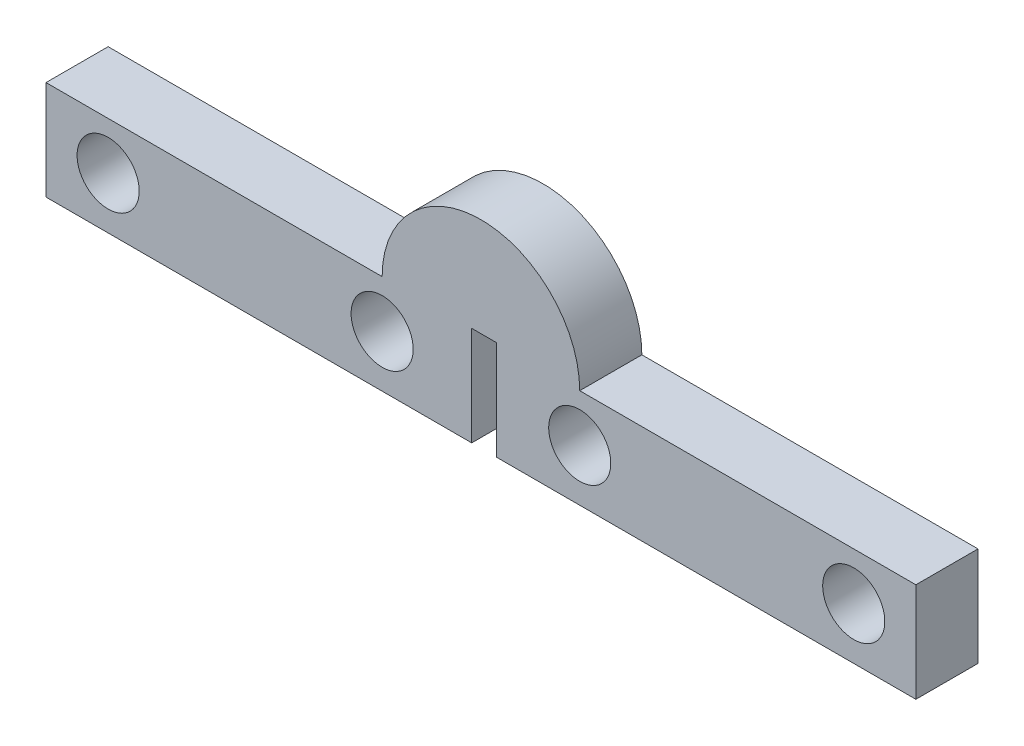
from build123d import *

# Parameters (mm, degrees)
SKETCH1_R           = 1.5
BOSS_EXTRUDE1_DEPTH = 3
SKETCH2_W           = 1.19
SKETCH2_H           = 4.79
CUT_EXTRUDE1_DEPTH  = 10


with BuildPart() as part:
    # Sketch1 → Boss-Extrude1 (new body)
    with BuildSketch(Plane.XY):
        with BuildLine():
            Line((20.555, 4.79), (20.555, 0))
            Line((20.555, 0), (0, 0))
            Line((0, 0), (0, 4.79))
            Line((0, 4.79), (16.23, 4.79))
            ThreePointArc((16.23, 4.79), (17.627100654, 8.162899346), (21, 9.56))
            Line((21, 9.56), (21, 4.79))
            Line((21, 4.79), (20.555, 4.79))
        make_face()
        with Locations((3, 2.5)):
            Circle(SKETCH1_R, mode=Mode.SUBTRACT)
        with Locations((16.23, 2.5)):
            Circle(SKETCH1_R, mode=Mode.SUBTRACT)
    boss_extrude1 = extrude(amount=BOSS_EXTRUDE1_DEPTH)

    # Mirror1: Boss-Extrude1 across plane
    add(boss_extrude1.mirror(Plane(origin=(21, 9.56, 3), x_dir=(0, 0, 1), z_dir=(-1, 0, 0))))

    # Sketch2 → Cut-Extrude1 (cut)
    with BuildSketch(Plane.XY.offset(3)):
        with Locations((21.15, 2.395)):
            Rectangle(SKETCH2_W, SKETCH2_H)
    extrude(amount=-CUT_EXTRUDE1_DEPTH, mode=Mode.SUBTRACT)


solid = part.part
